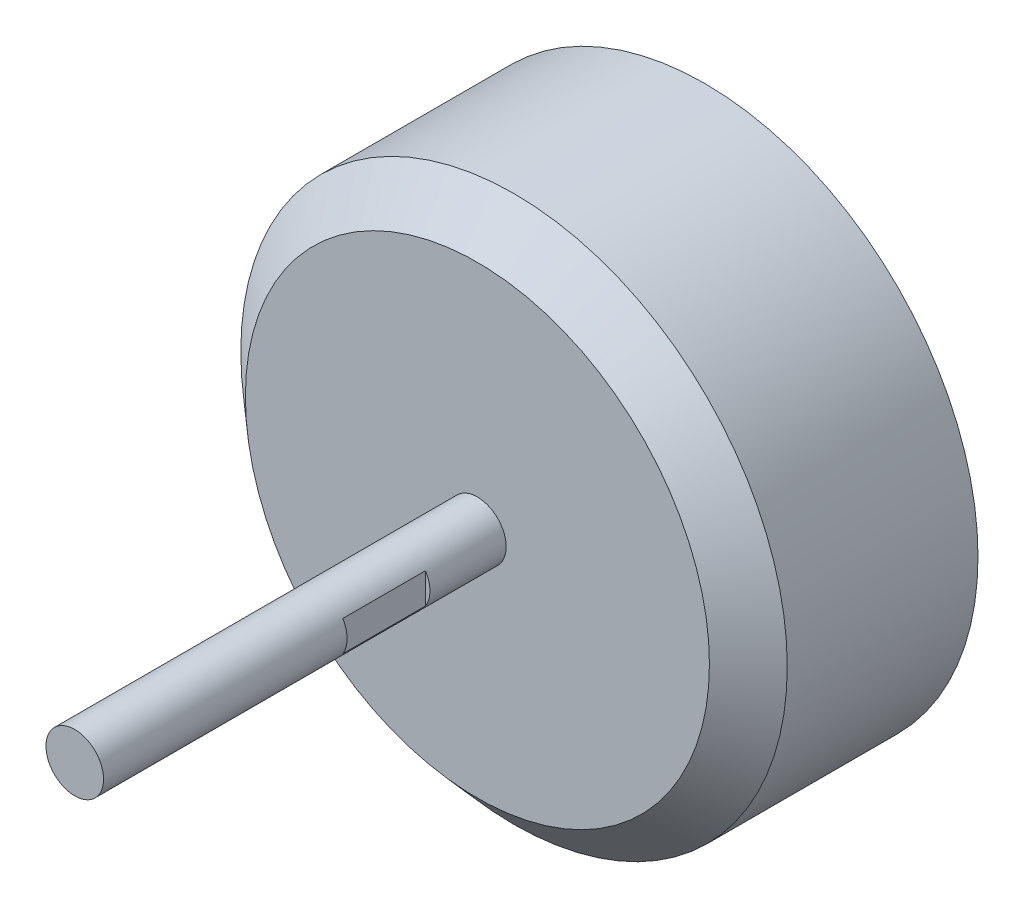
from build123d import *

# Parameters (mm, degrees)
SKETCH1_R                = 14.325
SKETCH1_R_2              = 13.825
BOSS_EXTRUDE1_DEPTH      = 10
SKETCH2_R                = 14.325
SKETCH3_R                = 12.165
SKETCH5_R                = 1.51
BOSS_EXTRUDE3_DEPTH      = 21.11
BOSS_EXTRUDE3_DEPTH_BACK = 17.23
SKETCH6_W                = 1
SKETCH6_H                = 4.34
CUT_EXTRUDE1_DEPTH       = 15.3250001
CUT_EXTRUDE1_DEPTH_BACK  = 15.3250001


with BuildPart() as part:
    # Sketch1 → Boss-Extrude1 (new body)
    with BuildSketch(Plane.XY):
        Circle(SKETCH1_R)
        Circle(SKETCH1_R_2, mode=Mode.SUBTRACT)
    extrude(amount=BOSS_EXTRUDE1_DEPTH)

    # Sketch2 → Loft1 section 0
    with BuildSketch(Plane.XY.offset(10)):
        Circle(SKETCH2_R)
    # Sketch3 → Loft1 section 1
    with BuildSketch(Plane.XY.offset(11.92)):
        Circle(SKETCH3_R)
    loft()

    # Sketch5 → Boss-Extrude3 (add, two sides)
    with BuildSketch(Plane.XY.offset(11.92)) as boss_extrude3_sk:
        Circle(SKETCH5_R)
    extrude(amount=BOSS_EXTRUDE3_DEPTH)
    extrude(boss_extrude3_sk.sketch, amount=-BOSS_EXTRUDE3_DEPTH_BACK)

    # Sketch6 → Cut-Extrude1 (cut, two sides)
    with BuildSketch(Plane(origin=(0, 0, 0), x_dir=(1, 0, 0), z_dir=(0, 1, 0))) as cut_extrude1_sk:
        with Locations((-1.78, -18.09)):
            Rectangle(SKETCH6_W, SKETCH6_H)
        with Locations((1.78, -18.09)):
            Rectangle(SKETCH6_W, SKETCH6_H)
    extrude(amount=CUT_EXTRUDE1_DEPTH, mode=Mode.SUBTRACT)
    extrude(cut_extrude1_sk.sketch, amount=-CUT_EXTRUDE1_DEPTH_BACK, mode=Mode.SUBTRACT)


solid = part.part
